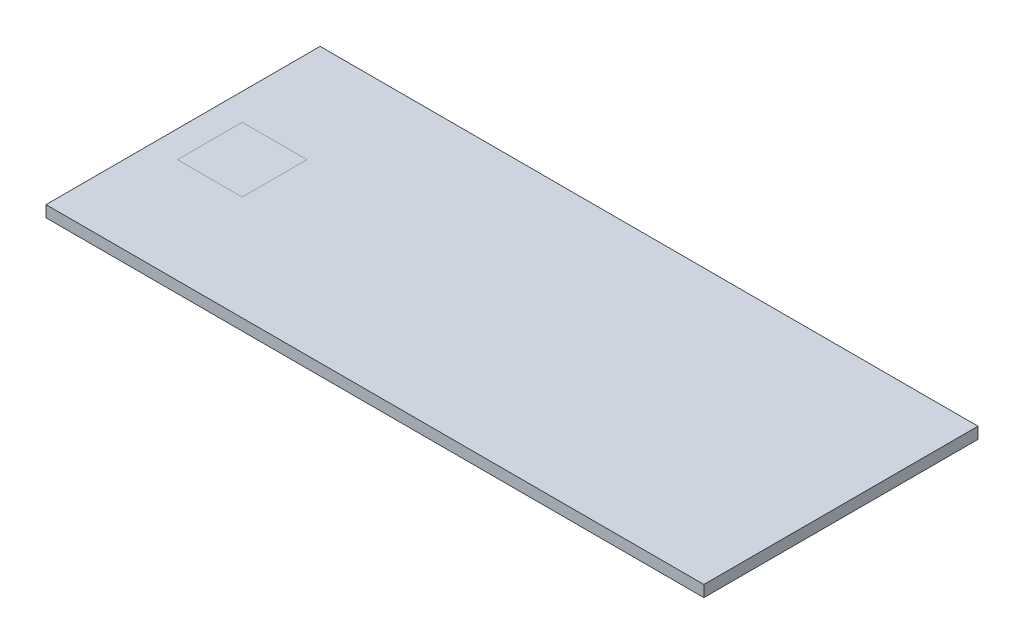
from build123d import *

# Parameters (mm, degrees)
BOSS_EXTRUDE1_DEPTH = 914.4
BOSS_EXTRUDE2_DEPTH = 381


with BuildPart() as part:
    # Sketch1 → Boss-Extrude1 (new body, symmetric)
    with BuildSketch(Plane(origin=(0, 0, 0), x_dir=(0, 0, -1), z_dir=(1, 0, 0))):
        Polygon((-381, 0), (381, 0), (381, -31.75), (349.25, -31.75), (349.25, -27.178), (376.428, -27.178), (376.428, -4.572), (-376.428, -4.572), (-376.428, -27.178), (-349.25, -27.178), (-349.25, -31.75), (-381, -31.75), align=None)
    extrude(amount=BOSS_EXTRUDE1_DEPTH, both=True)

    # Sketch2 → Boss-Extrude2 (add, symmetric)
    with BuildSketch(Plane.XY):
        Polygon((-914.4, 0), (-914.4, -31.75), (-882.65, -31.75), (-882.65, -27.178), (-909.828, -27.178), (-909.828, 0), align=None)
        Polygon((909.828, 0), (914.4, 0), (914.4, -31.75), (882.65, -31.75), (882.65, -27.178), (909.828, -27.178), align=None)
    extrude(amount=BOSS_EXTRUDE2_DEPTH, both=True)


solid = part.part
